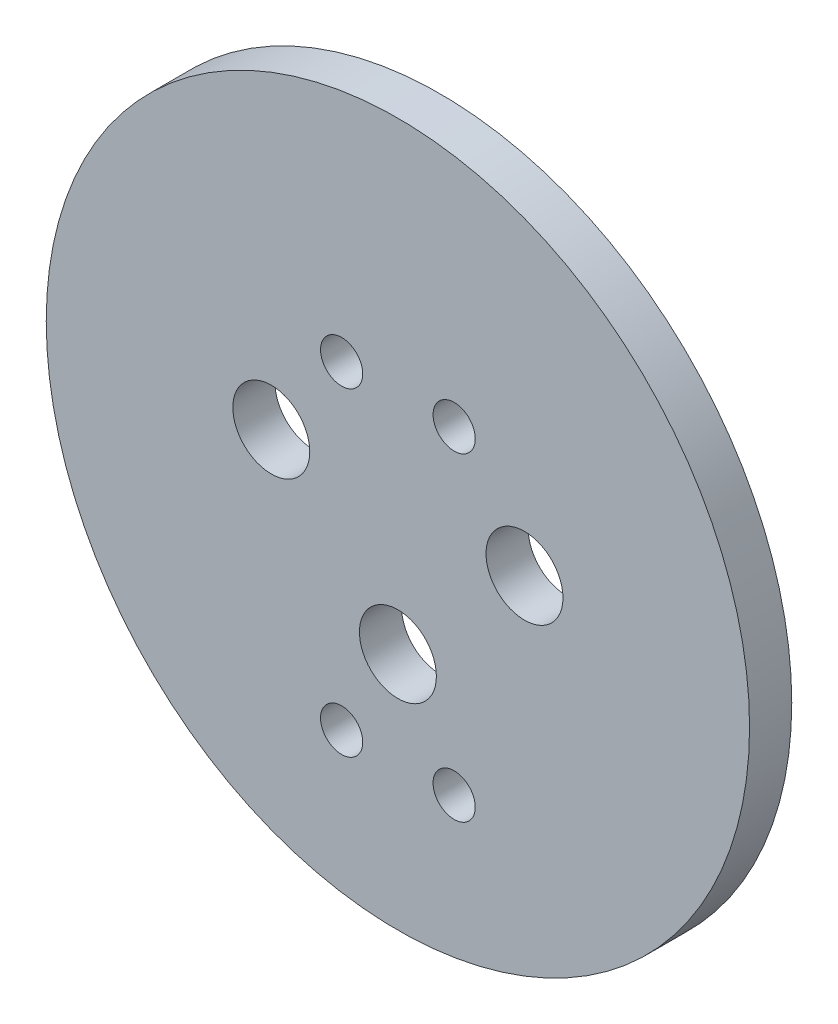
from build123d import *

# Parameters (mm, degrees)
SKETCH1_R           = 25
BOSS_EXTRUDE1_DEPTH = 3
SKETCH3_R           = 1.5
SKETCH3_R_2         = 2.735
CUT_EXTRUDE1_DEPTH  = 3


with BuildPart() as part:
    # Sketch1 → Boss-Extrude1 (new body)
    with BuildSketch(Plane.XY):
        Circle(SKETCH1_R)
    extrude(amount=BOSS_EXTRUDE1_DEPTH)

    # Sketch3 → Cut-Extrude1 (cut)
    with BuildSketch(Plane.XY.offset(3)):
        with Locations((-4, 8)):
            Circle(SKETCH3_R)
        with Locations((4, 8)):
            Circle(SKETCH3_R)
        with Locations((4, -14.677925359)):
            Circle(SKETCH3_R)
        with Locations((-4, -14.677925359)):
            Circle(SKETCH3_R)
        with Locations((0, -8)):
            Circle(SKETCH3_R_2)
        with Locations((9, 1.323807579)):
            Circle(SKETCH3_R_2)
        with Locations((-9, 1.323807579)):
            Circle(SKETCH3_R_2)
    extrude(amount=-CUT_EXTRUDE1_DEPTH, mode=Mode.SUBTRACT)


solid = part.part
